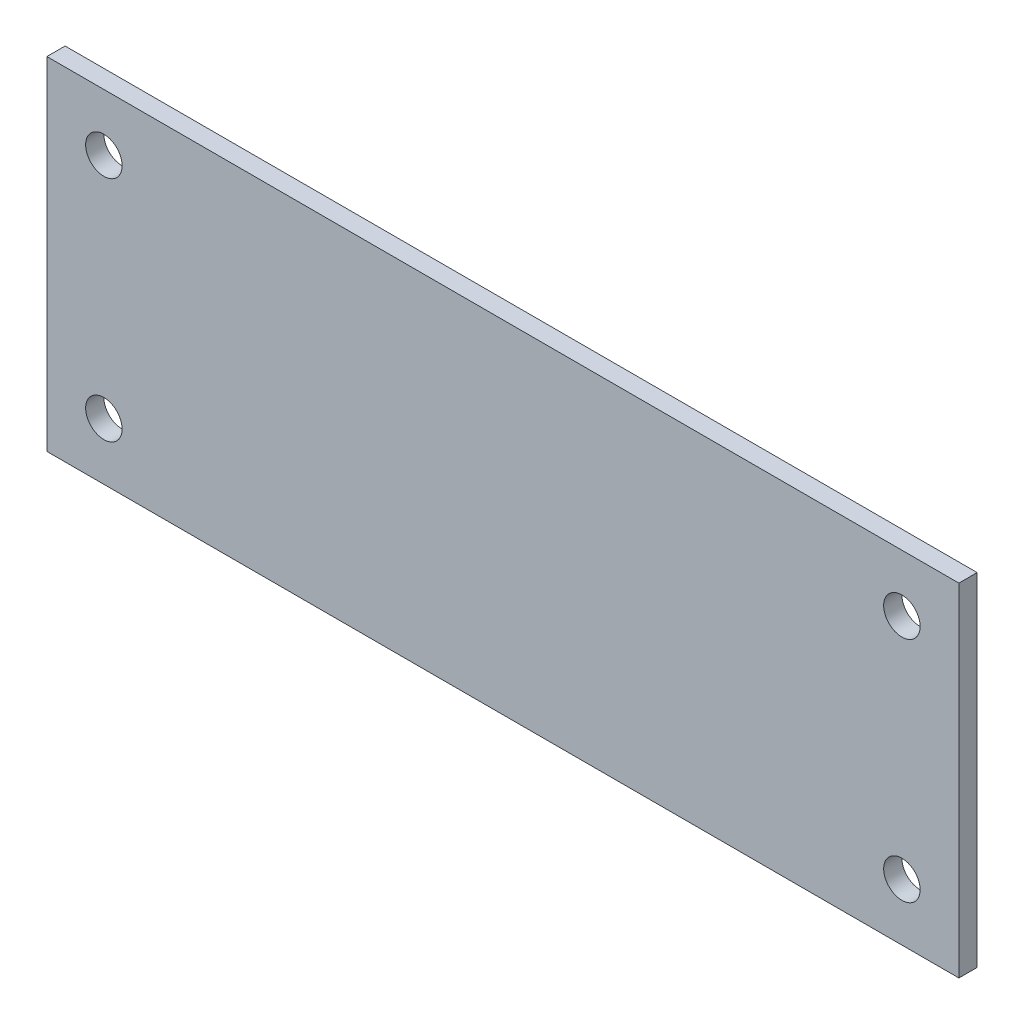
from build123d import *

# Parameters (mm, degrees)
ESQUISSE1_W        = 80
ESQUISSE1_H        = 30
ESQUISSE1_R        = 1.6
BOSS_EXTRU_1_DEPTH = 1.6


with BuildPart() as part:
    # Esquisse1 → Boss.-Extru.1 (new body)
    with BuildSketch(Plane.XY):
        Rectangle(ESQUISSE1_W, ESQUISSE1_H)
        with Locations((-35, 10)):
            Circle(ESQUISSE1_R, mode=Mode.SUBTRACT)
        with Locations((35, 10)):
            Circle(ESQUISSE1_R, mode=Mode.SUBTRACT)
        with Locations((35, -10)):
            Circle(ESQUISSE1_R, mode=Mode.SUBTRACT)
        with Locations((-35, -10)):
            Circle(ESQUISSE1_R, mode=Mode.SUBTRACT)
    extrude(amount=BOSS_EXTRU_1_DEPTH)


solid = part.part
